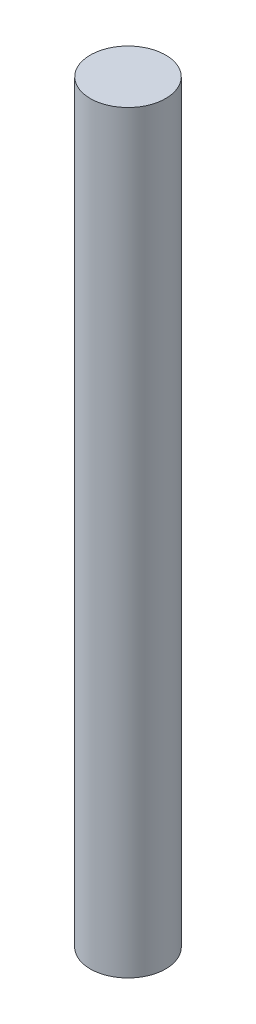
from build123d import *

# Parameters (mm, degrees)
ESQUISSE1_R      = 1.5
EXTRUSION1_DEPTH = 30


with BuildPart() as part:
    # Esquisse1 → Extrusion1 (new body)
    with BuildSketch(Plane(origin=(0, 0, 0), x_dir=(1, 0, 0), z_dir=(0, 1, 0))):
        Circle(ESQUISSE1_R)
    extrude(amount=EXTRUSION1_DEPTH)


solid = part.part
